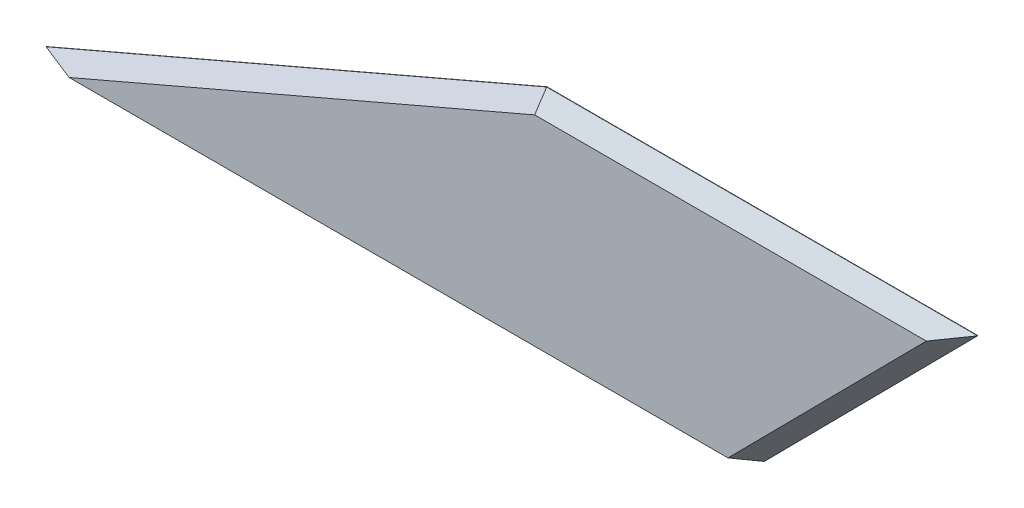
from build123d import *

# Parameters (mm, degrees)
SALIENTE_EXTRUIR1_DEPTH    = 2.125
CROQUIS3_R                 = 2
CORTAR_EXTRUIR1_DEPTH      = 1
CORTAR_EXTRUIR1_DEPTH_BACK = 10
CHAMFER1_SIZE              = 2.1


with BuildPart() as part:
    # Croquis1 → Saliente-Extruir1 (new body, symmetric)
    with BuildSketch(Plane.XY):
        Polygon((0, 0), (100, 0), (129.7, 30), (69.7, 30), align=None)
    extrude(amount=SALIENTE_EXTRUIR1_DEPTH, both=True)

    # Croquis3 → Cortar-Extruir1 (cut, two sides)
    with BuildSketch(Plane.XZ) as cortar_extruir1_sk:
        with Locations((73, 0)):
            Circle(CROQUIS3_R)
    extrude(amount=CORTAR_EXTRUIR1_DEPTH, mode=Mode.SUBTRACT)
    extrude(cortar_extruir1_sk.sketch, amount=-CORTAR_EXTRUIR1_DEPTH_BACK, mode=Mode.SUBTRACT)

    # Chamfer1
    chamfer1_edges = [part.edges().sort_by_distance(p)[0] for p in [
        (114.85, 15, 2.125),
        (99.7, 30, 2.125),
        (34.85, 15, 2.125),
        (99.7, 30, -2.125),
        (114.85, 15, -2.125),
        (34.85, 15, -2.125),
    ]]
    chamfer(chamfer1_edges, length=CHAMFER1_SIZE)


solid = part.part
